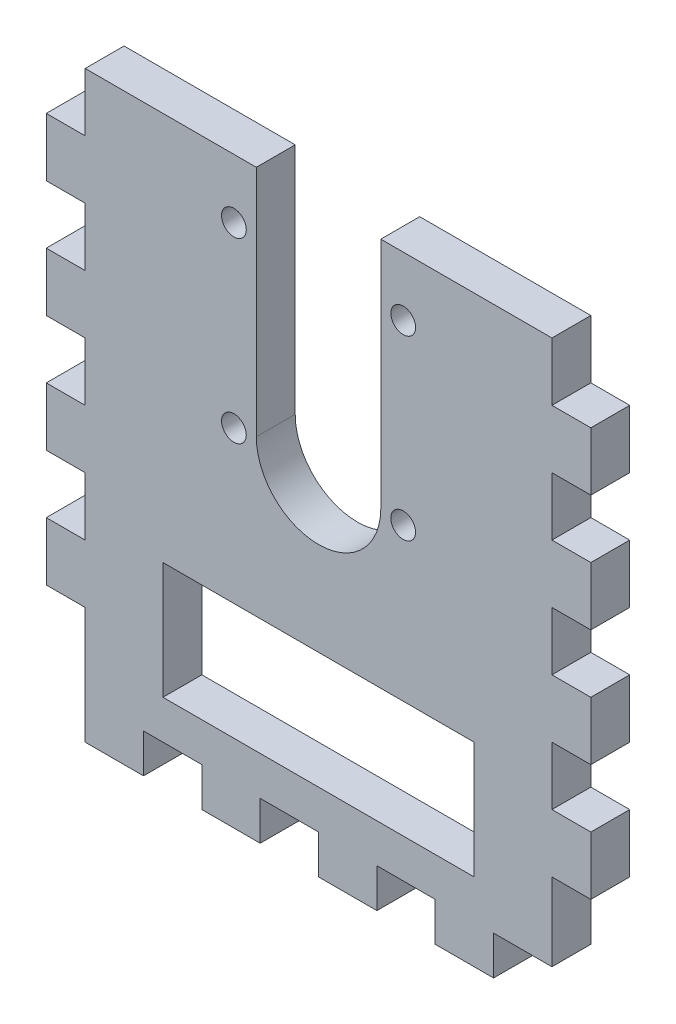
from build123d import *

# Parameters (mm, degrees)
SKETCH1_W           = 76.2
SKETCH1_H           = 88.9
BOSS_EXTRUDE1_DEPTH = 6.35
SKETCH2_R           = 2.0193
SKETCH2_W           = 50.8
SKETCH2_H           = 19.05
CUT_EXTRUDE1_DEPTH  = 6.35
SKETCH3_W           = 6.35
SKETCH3_H           = 9.525
SKETCH3_W_2         = 9.525
SKETCH3_H_2         = 6.35
BOSS_EXTRUDE3_DEPTH = 6.35


with BuildPart() as part:
    # Sketch1 → Boss-Extrude1 (new body)
    with BuildSketch(Plane.XY):
        with Locations((38.1, -44.45)):
            Rectangle(SKETCH1_W, SKETCH1_H)
    extrude(amount=BOSS_EXTRUDE1_DEPTH)

    # Sketch2 → Cut-Extrude1 (cut)
    with BuildSketch(Plane.XY.offset(6.35)):
        with Locations((51.9176, -9.652)):
            Circle(SKETCH2_R)
        with Locations((51.9176, -38.608)):
            Circle(SKETCH2_R)
        with Locations((24.2824, -38.6842)):
            Circle(SKETCH2_R)
        with Locations((24.2824, -9.652)):
            Circle(SKETCH2_R)
        with BuildLine():
            Line((48.26, 0), (48.26, -38.1))
            ThreePointArc((48.26, -38.1), (38.1, -48.26), (27.94, -38.1))
            Line((27.94, -38.1), (27.94, 0))
            ThreePointArc((27.94, 0), (38.1, 10.16), (48.26, 0))
        make_face()
        with Locations((38.1, -73.025)):
            Rectangle(SKETCH2_W, SKETCH2_H)
    extrude(amount=-CUT_EXTRUDE1_DEPTH, mode=Mode.SUBTRACT)

    # Sketch3 → Boss-Extrude3 (add)
    with BuildSketch(Plane.XY):
        with Locations((-3.175, -14.2875)):
            Rectangle(SKETCH3_W, SKETCH3_H)
        with Locations((-3.175, -33.3375)):
            Rectangle(SKETCH3_W, SKETCH3_H)
        with Locations((-3.175, -52.3875)):
            Rectangle(SKETCH3_W, SKETCH3_H)
        with Locations((-3.175, -71.4375)):
            Rectangle(SKETCH3_W, SKETCH3_H)
        with Locations((4.7625, -92.075)):
            Rectangle(SKETCH3_W_2, SKETCH3_H_2)
        with Locations((23.8125, -92.075)):
            Rectangle(SKETCH3_W_2, SKETCH3_H_2)
        with Locations((42.8625, -92.075)):
            Rectangle(SKETCH3_W_2, SKETCH3_H_2)
        with Locations((61.9125, -92.075)):
            Rectangle(SKETCH3_W_2, SKETCH3_H_2)
        with Locations((79.375, -71.4375)):
            Rectangle(SKETCH3_W, SKETCH3_H)
        with Locations((79.375, -52.3875)):
            Rectangle(SKETCH3_W, SKETCH3_H)
        with Locations((79.375, -33.3375)):
            Rectangle(SKETCH3_W, SKETCH3_H)
        with Locations((79.375, -14.2875)):
            Rectangle(SKETCH3_W, SKETCH3_H)
    extrude(amount=BOSS_EXTRUDE3_DEPTH)


solid = part.part
